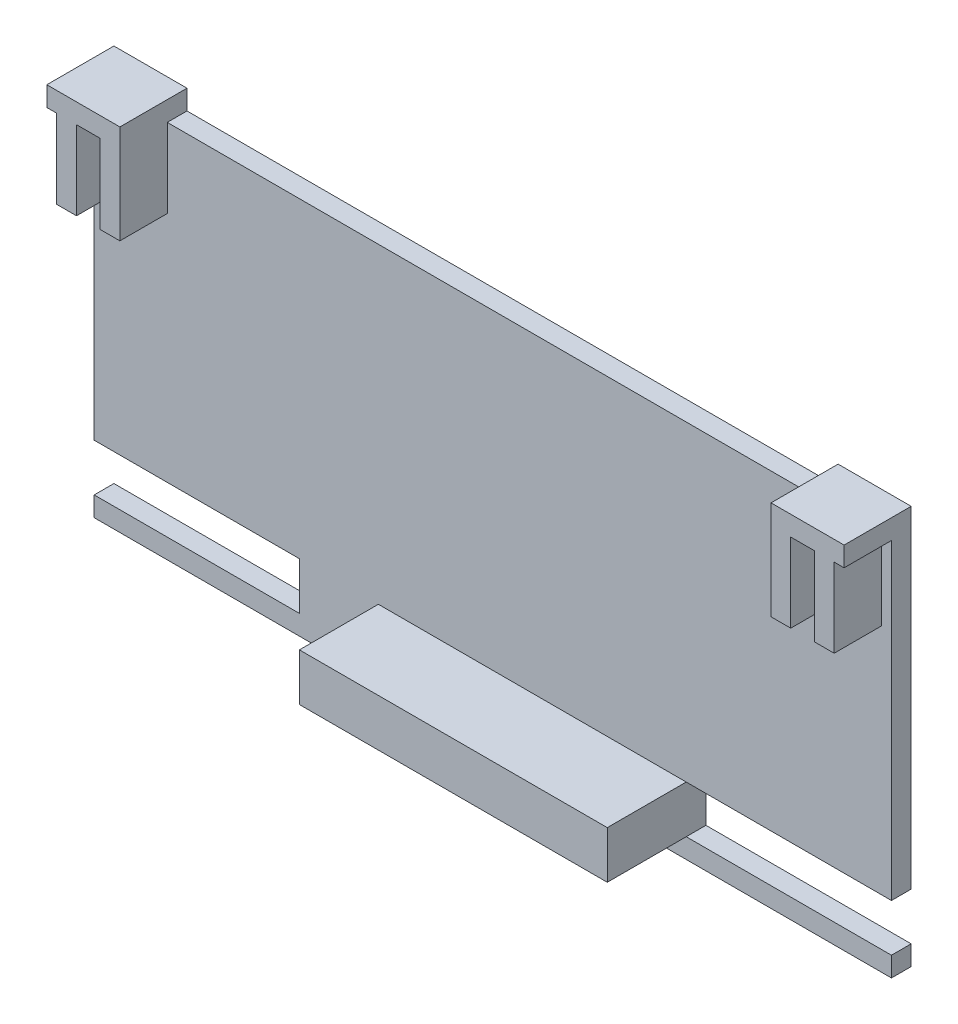
from build123d import *

# Parameters (mm, degrees)
SKETCH1_W           = 50.5
SKETCH1_H           = 24
BOSS_EXTRUDE1_DEPTH = 1.25
SKETCH2_W           = 1.25
SKETCH2_H           = 3
BOSS_EXTRUDE2_DEPTH = 5
SKETCH3_W           = 13
SKETCH3_H           = 3
CUT_EXTRUDE1_DEPTH  = 1.25
SKETCH5_W           = 4.628536498
SKETCH5_H           = 4.25
BOSS_EXTRUDE3_DEPTH = 1.25
SKETCH9_W           = 19.5
SKETCH9_H           = 3
BOSS_EXTRUDE5_DEPTH = 5


with BuildPart() as part:
    # Sketch1 → Boss-Extrude1 (new body)
    with BuildSketch(Plane.XY):
        with Locations((24, 12)):
            Rectangle(SKETCH1_W, SKETCH1_H)
    extrude(amount=BOSS_EXTRUDE1_DEPTH)

    # Sketch2 → Boss-Extrude2 (add)
    with BuildSketch(Plane(origin=(0, 24, 0), x_dir=(1, 0, 0), z_dir=(0, 1, 0))):
        with Locations((47.996463502, -2.75)):
            Rectangle(SKETCH2_W, SKETCH2_H)
        with Locations((45.246463502, -2.75)):
            Rectangle(SKETCH2_W, SKETCH2_H)
        with Locations((2.753536498, -2.75)):
            Rectangle(SKETCH2_W, SKETCH2_H)
        with Locations((0.003536498, -2.75)):
            Rectangle(SKETCH2_W, SKETCH2_H)
    extrude(amount=-BOSS_EXTRUDE2_DEPTH)

    # Sketch3 → Cut-Extrude1 (cut)
    with BuildSketch(Plane(origin=(0, 0, 0), x_dir=(-1, 0, 0), z_dir=(0, 0, -1))):
        with Locations((-42.75, 2.75)):
            Rectangle(SKETCH3_W, SKETCH3_H)
        with Locations((-5.25, 2.75)):
            Rectangle(SKETCH3_W, SKETCH3_H)
    extrude(amount=-CUT_EXTRUDE1_DEPTH, mode=Mode.SUBTRACT)

    # Sketch5 → Boss-Extrude3 (add)
    with BuildSketch(Plane(origin=(0, 24, 0), x_dir=(1, 0, 0), z_dir=(0, 1, 0))):
        with Locations((1.064268249, -2.125)):
            Rectangle(SKETCH5_W, SKETCH5_H)
        with Locations((46.935731751, -2.125)):
            Rectangle(SKETCH5_W, SKETCH5_H)
    extrude(amount=BOSS_EXTRUDE3_DEPTH)

    # Sketch9 → Boss-Extrude5 (add)
    with BuildSketch(Plane.XY.offset(1.25)):
        with Locations((26.5, 2.75)):
            Rectangle(SKETCH9_W, SKETCH9_H)
    extrude(amount=BOSS_EXTRUDE5_DEPTH)


solid = part.part
